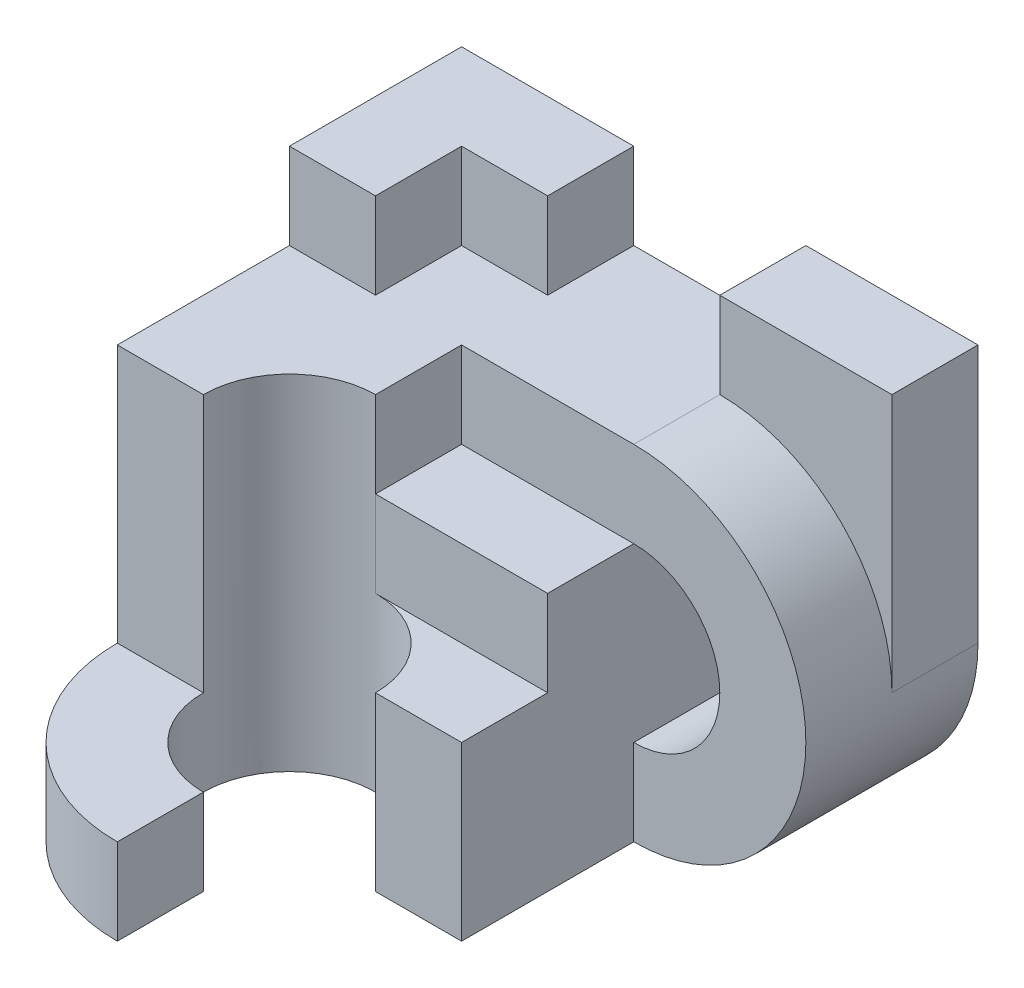
from build123d import *

# Parameters (mm, degrees)
SKETCH1_W           = 15
SKETCH1_H           = 15
BOSS_EXTRUDE1_DEPTH = 15
BOSS_EXTRUDE2_DEPTH = 10
SKETCH3_W           = 5
SKETCH3_H           = 15
BOSS_EXTRUDE3_DEPTH = 5
SKETCH5_W           = 5
SKETCH5_H           = 15
BOSS_EXTRUDE4_DEPTH = 20
BOSS_EXTRUDE5_DEPTH = 20
BOSS_EXTRUDE6_DEPTH = 5
BOSS_EXTRUDE7_DEPTH = 10
SKETCH12_W          = 10
SKETCH12_H          = 5
BOSS_EXTRUDE8_DEPTH = 15
CUT_EXTRUDE1_DEPTH  = 15
BOSS_EXTRUDE9_DEPTH = 5


with BuildPart() as part:
    # Sketch1 → Boss-Extrude1 (new body)
    with BuildSketch(Plane.XY):
        Rectangle(SKETCH1_W, SKETCH1_H)
    extrude(amount=BOSS_EXTRUDE1_DEPTH)

    # Sketch2 → Boss-Extrude2 (add)
    with BuildSketch(Plane.XY):
        with BuildLine():
            Line((7.5, 12.5), (-2.5, 12.5))
            Line((-2.5, 12.5), (-2.5, 7.5))
            Line((-2.5, 7.5), (7.5, 7.5))
            ThreePointArc((7.5, 7.5), (12.5, 2.5), (7.5, -2.5))
            Line((7.5, -2.5), (7.5, -7.5))
            ThreePointArc((7.5, -7.5), (17.5, 2.5), (7.5, 12.5))
        make_face()
    extrude(amount=BOSS_EXTRUDE2_DEPTH)

    # Sketch3 → Boss-Extrude3 (add)
    with BuildSketch(Plane(origin=(0, 7.5, 0), x_dir=(1, 0, 0), z_dir=(0, 1, 0))):
        with Locations((-5, -7.5)):
            Rectangle(SKETCH3_W, SKETCH3_H)
    extrude(amount=BOSS_EXTRUDE3_DEPTH)

    # Sketch5 → Boss-Extrude4 (add)
    with BuildSketch(Plane(origin=(0, -7.5, 0), x_dir=(1, 0, 0), z_dir=(0, 1, 0))):
        with Locations((-10, -7.5)):
            Rectangle(SKETCH5_W, SKETCH5_H)
    extrude(amount=BOSS_EXTRUDE4_DEPTH)

    # Sketch6 → Boss-Extrude5 (add)
    with BuildSketch(Plane(origin=(0, -7.5, 0), x_dir=(1, 0, 0), z_dir=(0, 1, 0))):
        with BuildLine():
            Line((-12.5, -15), (-12.5, -20))
            Line((-12.5, -20), (-7.5, -20))
            ThreePointArc((-7.5, -20), (-6.035533906, -16.464466094), (-2.5, -15))
            Line((-2.5, -15), (-12.5, -15))
        make_face()
    extrude(amount=BOSS_EXTRUDE5_DEPTH)

    # Sketch7 → Boss-Extrude6 (add)
    with BuildSketch(Plane(origin=(0, -7.5, 0), x_dir=(1, 0, 0), z_dir=(0, 1, 0))):
        with BuildLine():
            Line((-2.5, -25), (-2.5, -30))
            ThreePointArc((-2.5, -30), (-9.571067812, -27.071067812), (-12.5, -20))
            Line((-12.5, -20), (-7.5, -20))
            ThreePointArc((-7.5, -20), (-6.035533906, -23.535533906), (-2.5, -25))
        make_face()
    extrude(amount=BOSS_EXTRUDE6_DEPTH)

    # Sketch8 → Boss-Extrude7 (add)
    with BuildSketch(Plane(origin=(0, -7.5, 0), x_dir=(1, 0, 0), z_dir=(0, 1, 0))):
        with BuildLine():
            Line((7.5, -15), (7.5, -20))
            Line((7.5, -20), (2.5, -20))
            ThreePointArc((2.5, -20), (1.035533906, -16.464466094), (-2.5, -15))
            Line((-2.5, -15), (7.5, -15))
        make_face()
    extrude(amount=BOSS_EXTRUDE7_DEPTH)

    # Sketch12 → Boss-Extrude8 (add)
    with BuildSketch(Plane(origin=(0, 2.5, 0), x_dir=(1, 0, 0), z_dir=(0, 1, 0))):
        with Locations((12.5, -2.5)):
            Rectangle(SKETCH12_W, SKETCH12_H)
    extrude(amount=BOSS_EXTRUDE8_DEPTH)

    # Sketch13 → Cut-Extrude1 (cut)
    with BuildSketch(Plane.XY.offset(5)):
        with BuildLine():
            Line((12.5, 2.5), (7.5, 2.5))
            Line((7.5, 2.5), (7.5, 7.5))
            add(Edge.make_bspline(
                [(7.5, 7.5), (11.035533906, 7.5), (12.5, 2.5)],
                knots=[0, 0, 0, 1, 1, 1], degree=2))
        make_face()
    extrude(amount=-CUT_EXTRUDE1_DEPTH, mode=Mode.SUBTRACT)

    # Sketch14 → Boss-Extrude9 (add)
    with BuildSketch(Plane(origin=(0, 12.5, 0), x_dir=(1, 0, 0), z_dir=(0, 1, 0))):
        Polygon((-12.5, 0), (-2.5, 0), (-2.5, -5), (-7.5, -5), (-7.5, -10), (-12.5, -10), align=None)
    extrude(amount=BOSS_EXTRUDE9_DEPTH)


solid = part.part
